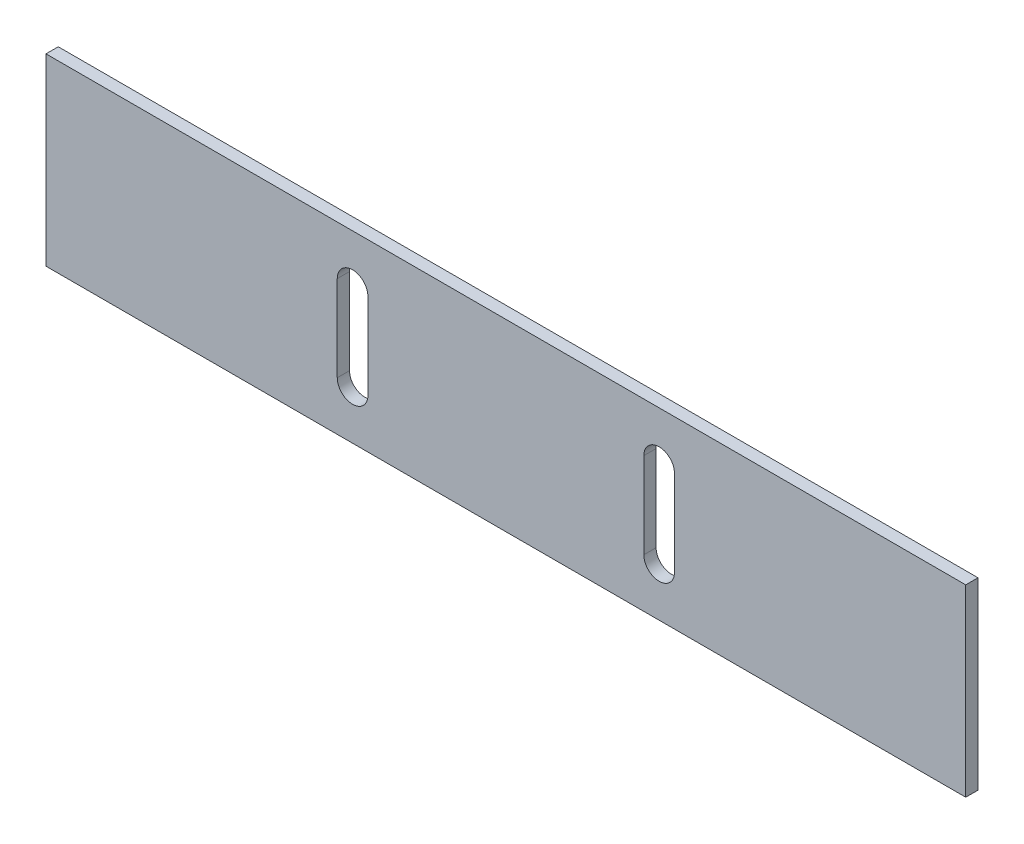
from build123d import *

# Parameters (mm, degrees)
SKETCH_1_W      = 150
SKETCH_1_H      = 30
EXTRUDE_1_DEPTH = 2


with BuildPart() as part:
    # Эскиз1 → Бобышка-Вытянуть1 (new body)
    with BuildSketch(Plane.XY):
        with Locations((75, 15)):
            Rectangle(SKETCH_1_W, SKETCH_1_H)
        with BuildLine():
            Line((47.5, 8), (47.5, 22))
            ThreePointArc((47.5, 22), (50, 24.5), (52.5, 22))
            Line((52.5, 22), (52.5, 8))
            ThreePointArc((52.5, 8), (50, 5.5), (47.5, 8))
        make_face(mode=Mode.SUBTRACT)
        with BuildLine():
            Line((97.5, 8), (97.5, 22))
            ThreePointArc((97.5, 22), (100, 24.5), (102.5, 22))
            Line((102.5, 22), (102.5, 8))
            ThreePointArc((102.5, 8), (100, 5.5), (97.5, 8))
        make_face(mode=Mode.SUBTRACT)
    extrude(amount=EXTRUDE_1_DEPTH)


solid = part.part
